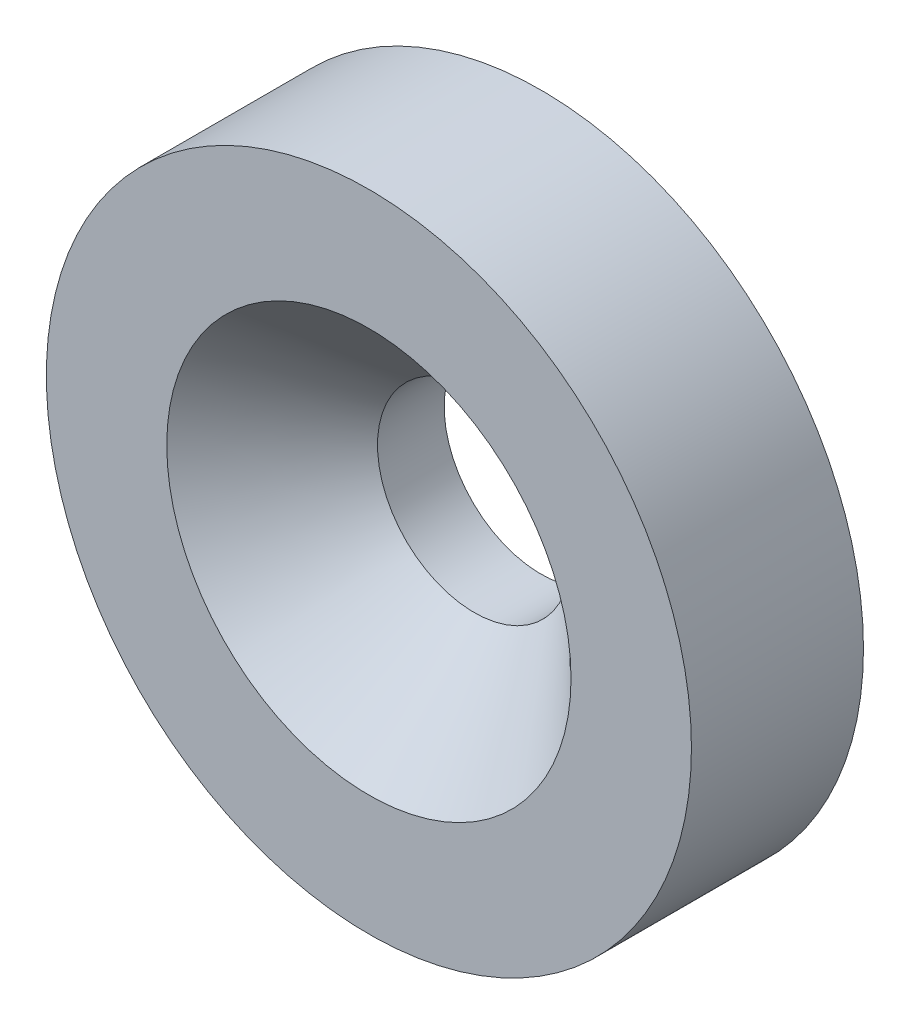
from build123d import *

# Parameters (mm, degrees)
SKETCH2_R           = 7.5
BOSS_EXTRUDE1_DEPTH = 4


with BuildPart() as part:
    # Sketch2 → Boss-Extrude1 (new body)
    with BuildSketch(Plane.XY):
        Circle(SKETCH2_R)
    extrude(amount=-BOSS_EXTRUDE1_DEPTH)

    # Sketch6 → CSK for M4 Flat Head Machine Screw1 (revolve, cut)
    with BuildSketch(Plane(origin=(0, 0, 0), x_dir=(0, -1, 0), z_dir=(1, 0, 0))):
        Polygon((0, 0), (0, 4), (2.25, 4), (2.25, 2.45), (4.7, 0), align=None)
    revolve(axis=Axis((0, 0, 6.35), (0, 0, -1)), mode=Mode.SUBTRACT)


solid = part.part
